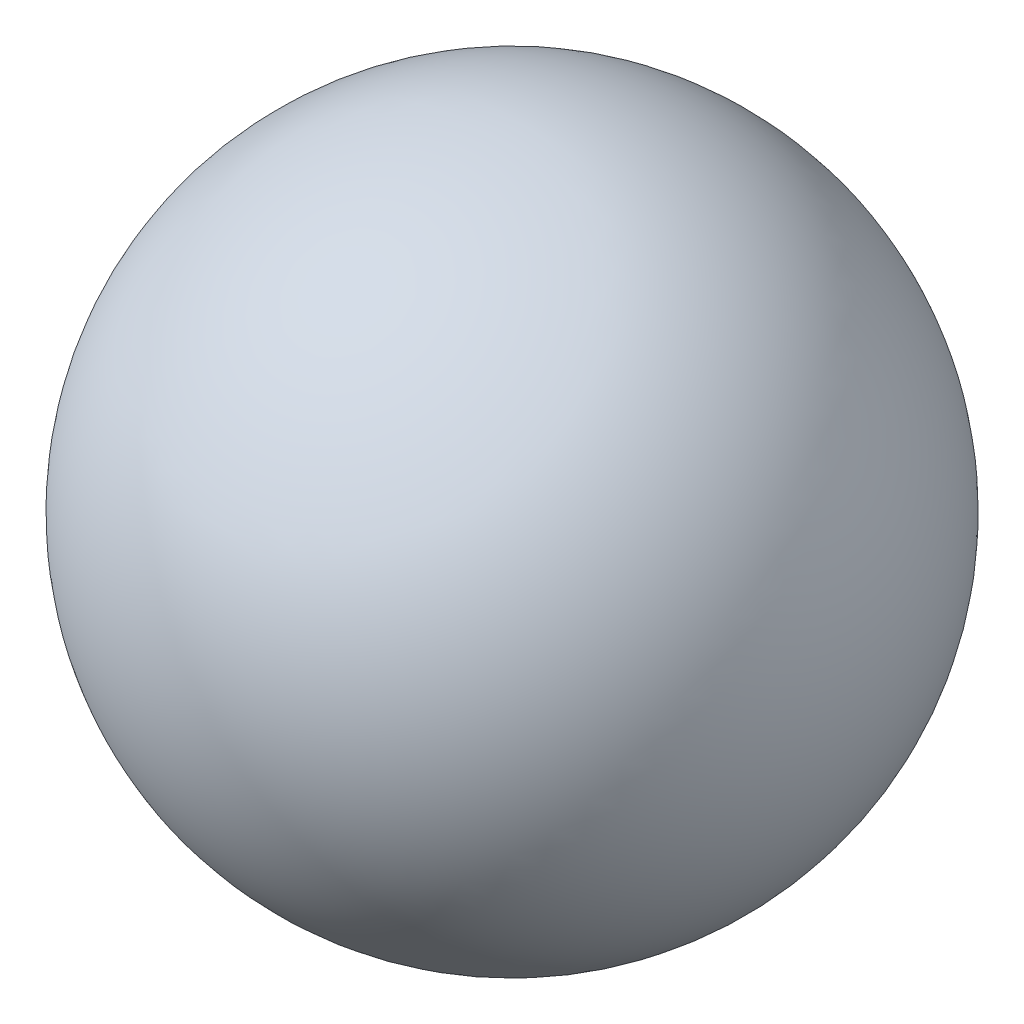
from build123d import *


with BuildPart() as part:
    # Sketch2 → Revolve2 (revolve)
    with BuildSketch(Plane(origin=(0, 0, 0), x_dir=(1, 0, 0), z_dir=(0, 1, 0))):
        with BuildLine():
            Line((0, 3.96875), (0, -3.96875))
            ThreePointArc((0, -3.96875), (-3.96875, 0), (0, 3.96875))
        make_face()
    revolve(axis=Axis((0, 0, 3.8125), (0, 0, -1)))


solid = part.part
